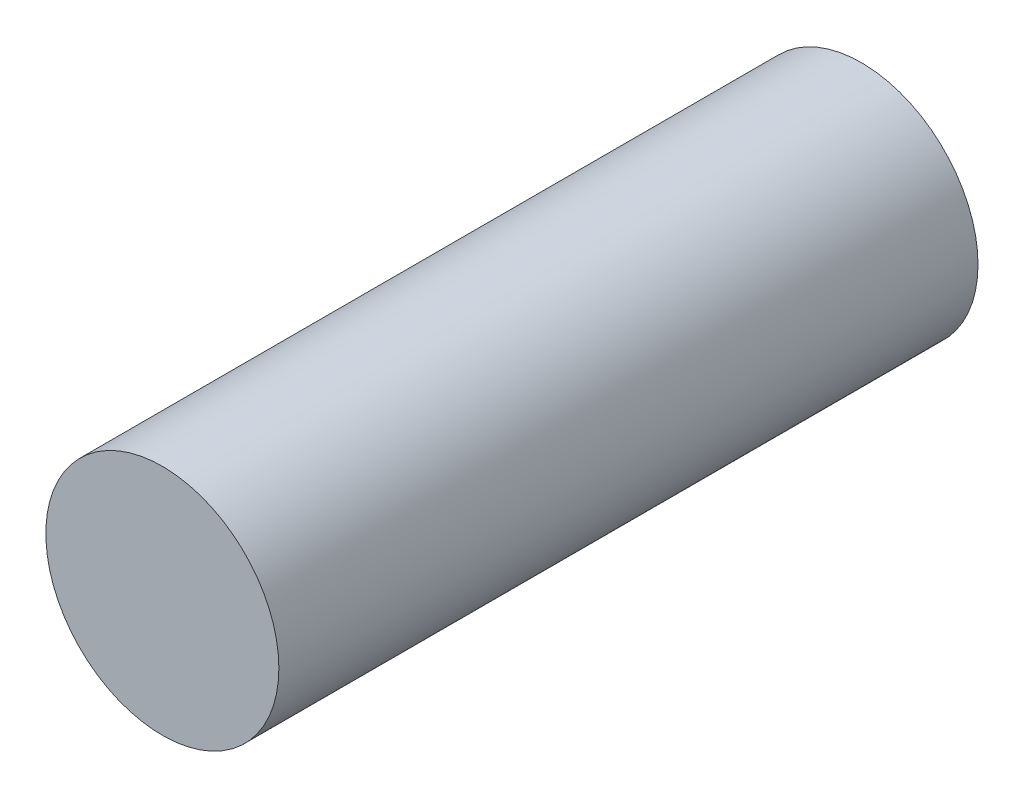
from build123d import *

# Parameters (mm, degrees)
ESQUISSE1_R        = 1
BOSS_EXTRU_1_DEPTH = 6


with BuildPart() as part:
    # Esquisse1 → Boss.-Extru.1 (new body)
    with BuildSketch(Plane.XY):
        Circle(ESQUISSE1_R)
    extrude(amount=BOSS_EXTRU_1_DEPTH)


solid = part.part
